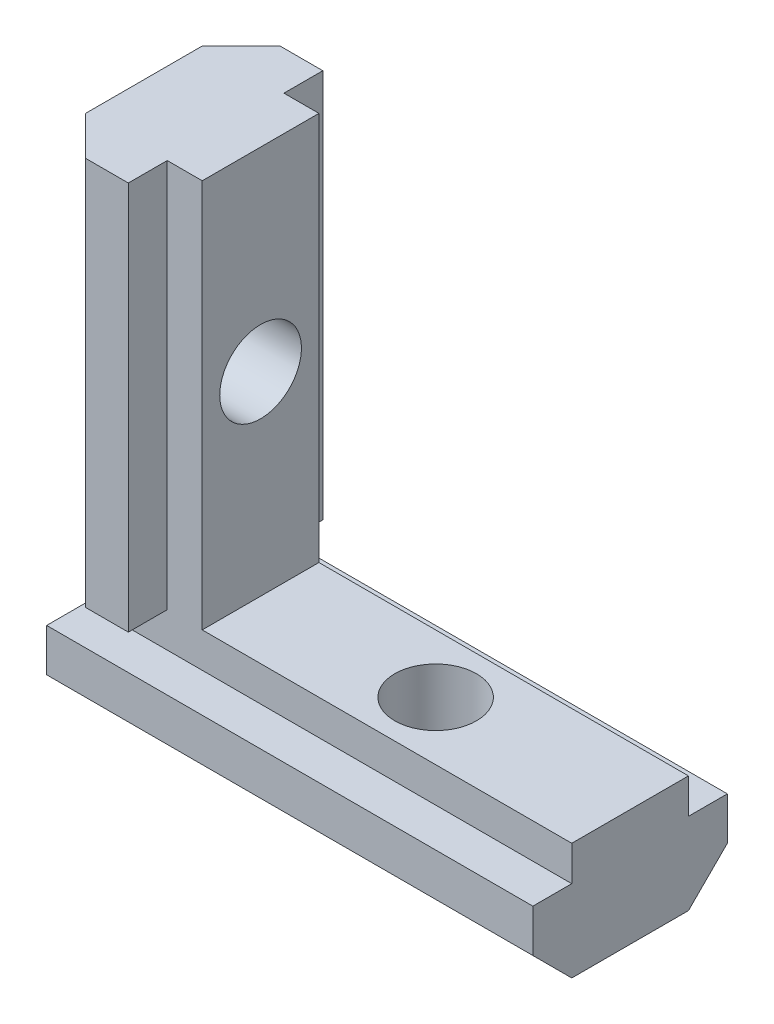
from build123d import *

# Parameters (mm, degrees)
EXTRUDE_1_DEPTH    = 20
EXTRUDE_2_DEPTH    = 25
HOLE_WIZARD_M5_1_D = 4.2
HOLE_WIZARD_M5_2_D = 4.2


with BuildPart() as part:
    # 草图1 → 凸台-拉伸1 (new body)
    with BuildSketch(Plane(origin=(0, 0, 0), x_dir=(1, 0, 0), z_dir=(0, 1, 0))):
        Polygon((-3, 3), (-3, -3), (-1, -5), (1.2, -5), (1.2, -3), (3, -3), (3, 3), (1.2, 3), (1.2, 5), (-1, 5), align=None)
    extrude(amount=EXTRUDE_1_DEPTH)

    # 草图3 → 凸台-拉伸2 (add)
    with BuildSketch(Plane.ZY.offset(3)):
        Polygon((-3, -6), (3, -6), (5, -4), (5, -1.8), (3, -1.8), (3, 0), (-3, 0), (-3, -1.8), (-5, -1.8), (-5, -4), align=None)
    extrude(amount=-EXTRUDE_2_DEPTH)

    # M5 螺纹孔1 (through all)
    with Locations(Plane.ZY.offset(3)):
        with Locations((0, 10)):
            Hole(HOLE_WIZARD_M5_1_D / 2)

    # M5 螺纹孔2 (through all)
    with Locations(Plane(origin=(0, -6, 0), x_dir=(-1, 0, 0), z_dir=(0, -1, 0))):
        with Locations((-12, 0)):
            Hole(HOLE_WIZARD_M5_2_D / 2)


solid = part.part
